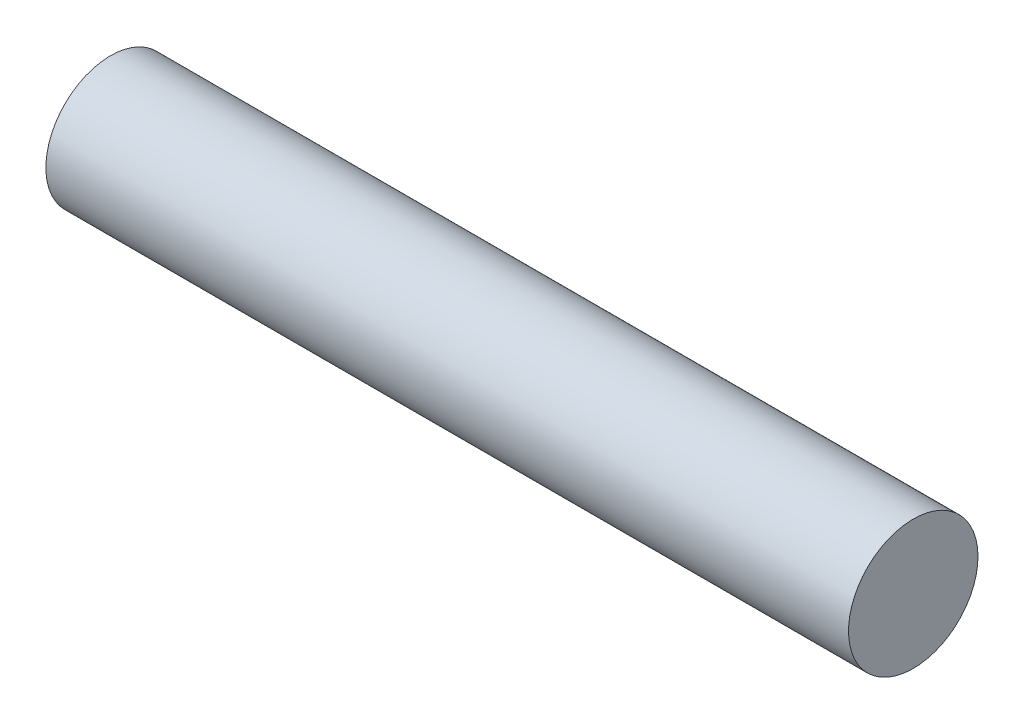
from build123d import *

# Parameters (mm, degrees)
SKETCH1_R           = 0.9525
BOSS_EXTRUDE1_DEPTH = 5.9055


with BuildPart() as part:
    # Sketch1 → Boss-Extrude1 (new body, symmetric)
    with BuildSketch(Plane(origin=(0, 0, 0), x_dir=(0, 0, -1), z_dir=(1, 0, 0))):
        Circle(SKETCH1_R)
    extrude(amount=BOSS_EXTRUDE1_DEPTH, both=True)


solid = part.part
